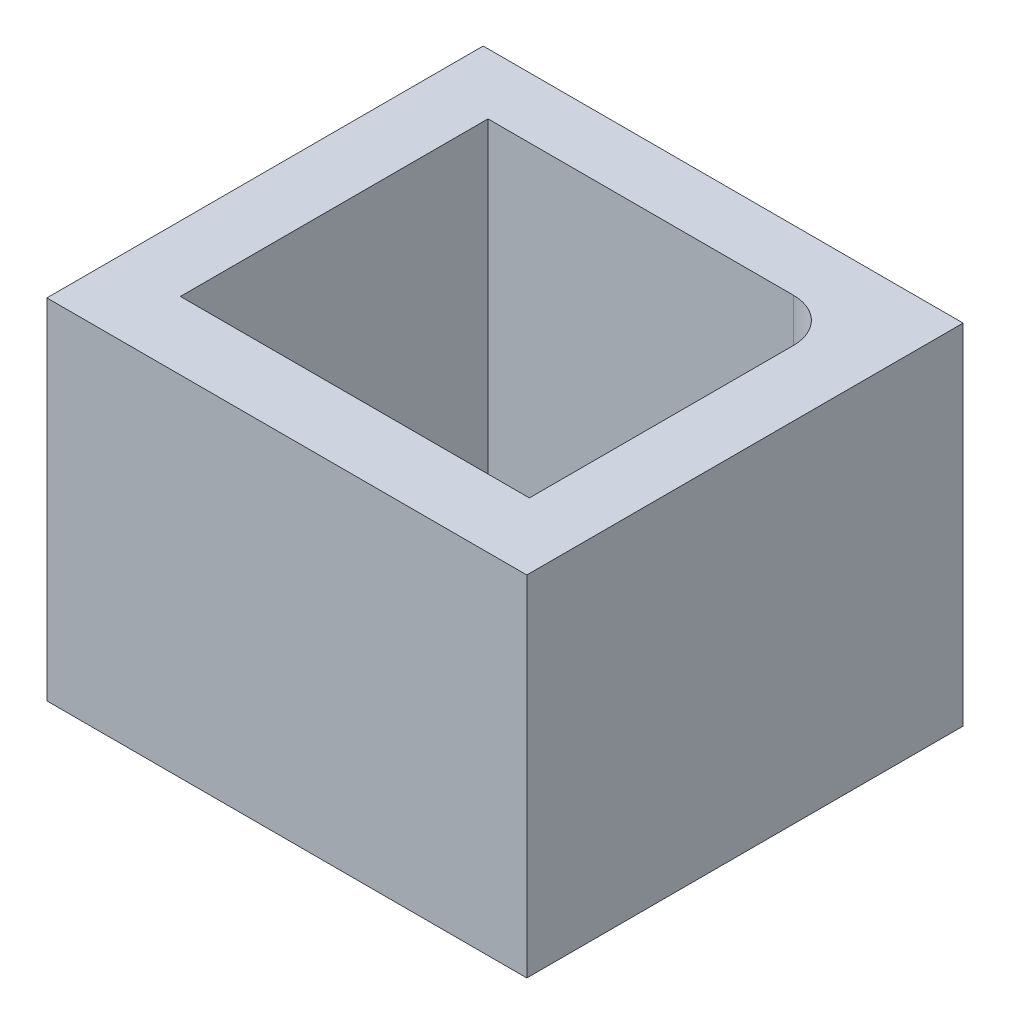
from build123d import *

# Parameters (mm, degrees)
CROQUIS1_R                              = 15.25
CROQUIS1_R_2                            = 2.125
SOPORTE_CAJA_REDUCTORA_DEPTH            = 20
CROQUIS3_R                              = 2.125
CORTAR_EXTRUIR1_DEPTH                   = 51.423828692
REDONDEO1_R                             = 5
BOSS_EXTRUDE1_DEPTH                     = 20
CUT_EXTRUDE1_REACH                      = 55.852
SKETCH2_R                               = 1.625
CUT_EXTRUDE2_DEPTH                      = 2
SKETCH4_R                               = 1.625
CUT_EXTRUDE3_DEPTH                      = 63.291652731
CUT_EXTRUDE4_START                      = -4.5
CUT_EXTRUDE4_DEPTH                      = 2
CROQUIS6_W                              = 4.75
CROQUIS6_H                              = 4.75
CORTAR_EXTRUIR17_DEPTH                  = 42.231056256
CROQUIS7_W                              = 60
CROQUIS7_H                              = 20
CORTAR_EXTRUIR18_DEPTH                  = 51.423828692
SALIENTE_EXTRUIR2_DEPTH                 = 49
SOPORTE_START                           = -15
SOPORTE_MOTOR_DEPTH                     = 15
CROQUIS12_R                             = 2.125
AGUJEROS_DE_SUJECION_A_BASE_DEPTH       = 84.087679592
TUERCA_START                            = -4
TUERCA_AGUJERO_DE_SUJECION_A_BASE_DEPTH = 10
SALIENTE_EXTRUIR4_DEPTH                 = 15
CORTAR_EXTRUIR19_DEPTH                  = 25
CROQUIS14_W                             = 50
CROQUIS14_H                             = 118
CORTAR_EXTRUIR22_DEPTH                  = 146.556045907
CROQUIS15_W                             = 10
CROQUIS15_H                             = 7
CORTAR_EXTRUIR23_DEPTH                  = 42.231056256
CORTAR_EXTRUIR24_DEPTH                  = 42.231056256
CROQUIS18_W                             = 40
CROQUIS18_H                             = 10
CORTAR_EXTRUIR25_DEPTH                  = 44.27311521
SALIENTE_EXTRUIR5_DEPTH                 = 10
CROQUIS20_R                             = 1
CORTAR_EXTRUIR26_DEPTH                  = 49.229270158
CORTAR_EXTRUIR27_REACH                  = 62.959
CORTAR_EXTRUIR27_END_RADIUS             = 15.25
CROQUIS21_R                             = 1.625
CROQUIS22_R                             = 2.125
CROQUIS22_R_2                           = 1
SALIENTE_EXTRUIR6_DEPTH                 = 10
CROQUIS23_R                             = 1.625
CORTAR_EXTRUIR28_DEPTH                  = 52.269508521
CORTAR_EXTRUIR29_START                  = -3
CORTAR_EXTRUIR29_DEPTH                  = 10
SALIENTE_EXTRUIR7_DEPTH                 = 10
CORTAR_EXTRUIR30_REACH                  = 72.235
CROQUIS27_R                             = 1.625
CORTAR_EXTRUIR31_REACH                  = 75.235
CORTAR_EXTRUIR31_START                  = -3
CORTAR_EXTRUIR32_REACH                  = 58.612
CROQUIS29_R                             = 1.625
CORTAR_EXTRUIR33_REACH                  = 61.112
CORTAR_EXTRUIR33_START                  = -2.5
CROQUIS35_W                             = 13.305418987
CROQUIS35_H                             = 6.826864192
CORTAR_EXTRUIR34_DEPTH                  = 63.931555098
CORTAR_EXTRUIR34_DEPTH_BACK             = 63.931555098
CORTAR_EXTRUIR35_START                  = -3
CORTAR_EXTRUIR35_DEPTH                  = 10
SALIENTE_EXTRUIR8_DEPTH                 = 10
SALIENTE_EXTRUIR9_DEPTH                 = 13
SALIENTE_EXTRUIR10_DEPTH                = 3
CROQUIS40_W                             = 106.583537839
CROQUIS40_H                             = 47.391515964
CORTAR_EXTRUIR36_DEPTH                  = 80.887064817
CORTAR_EXTRUIR36_DEPTH_BACK             = 80.887064817
CORTAR_EXTRUIR37_DEPTH                  = 67.2524009
CORTAR_EXTRUIR37_DEPTH_BACK             = 67.2524009
CORTAR_EXTRUIR38_DEPTH                  = 79.704784639
CORTAR_EXTRUIR38_DEPTH_BACK             = 79.704784639
SALIENTE_EXTRUIR11_DEPTH                = 10
CORTAR_EXTRUIR39_DEPTH                  = 63.9908649
CROQUIS45_W                             = 31.470301378
CROQUIS45_H                             = 10
CROQUIS45_R                             = 1.625
SALIENTE_EXTRUIR12_DEPTH                = 2.5
SALIENTE_EXTRUIR13_DEPTH                = 10
CORTAR_EXTRUIR40_START                  = -2
CROQUIS47_R                             = 1.625
CORTAR_EXTRUIR40_DEPTH                  = 10
CORTAR_EXTRUIR41_START                  = -12
CROQUIS48_R                             = 1.625
CORTAR_EXTRUIR41_DEPTH                  = 12
CROQUIS49_W                             = 34.796066513
CROQUIS49_H                             = 42.211026982
CORTAR_EXTRUIR42_DEPTH                  = 52.795622989
CORTAR_EXTRUIR42_DEPTH_BACK             = 52.795622989
CROQUIS51_R                             = 15.25
CROQUIS51_R_2                           = 14.25
SALIENTE_EXTRUIR14_DEPTH                = 10
CORTAR_EXTRUIR43_DEPTH                  = 10
CORTAR_EXTRUIR44_DEPTH                  = 10
CORTAR_EXTRUIR45_DEPTH                  = 10
SALIENTE_EXTRUIR15_DEPTH                = 10
CROQUIS56_W                             = 55
CROQUIS56_H                             = 50
SALIENTE_EXTRUIR16_DEPTH                = 5
CROQUIS57_W                             = 42.651963039
CROQUIS57_H                             = 12.802181648
CORTAR_EXTRUIR46_DEPTH                  = 71.545387859
CORTAR_EXTRUIR46_DEPTH_BACK             = 71.545387859
CROQUIS58_R                             = 2.125
CORTAR_EXTRUIR47_DEPTH                  = 5
CROQUIS59_W                             = 55
CROQUIS59_H                             = 50
SALIENTE_EXTRUIR17_DEPTH                = 40


with BuildPart() as part:
    # Croquis1 → Soporte caja reductora (new body)
    with BuildSketch(Plane(origin=(0, 0, 0), x_dir=(1, 0, 0), z_dir=(0, 1, 0))):
        Polygon((-30, -15.25), (-20, -15.25), (-20, -20), (20, -20), (20, -15.25), (30, -15.25), (30, -7.25), (20, -4.25), (20, 20), (-20, 20), (-20, -4.25), (-30, -7.25), align=None)
        with Locations(Location((0, 0, 0), (0, 0, 270))):
            Circle(CROQUIS1_R, mode=Mode.SUBTRACT)
        with Locations(Location((-15, 15, 0), (0, 0, 270))):
            Circle(CROQUIS1_R_2, mode=Mode.SUBTRACT)
        with Locations(Location((15, 15, 0), (0, 0, 270))):
            Circle(CROQUIS1_R_2, mode=Mode.SUBTRACT)
    extrude(amount=-SOPORTE_CAJA_REDUCTORA_DEPTH)

    # Croquis3 → Cortar-Extruir1 (cut, through all)
    with BuildSketch(Plane.XY.offset(15.25)):
        with Locations((-23.5, -10)):
            Circle(CROQUIS3_R)
        with Locations((23.5, -10)):
            Circle(CROQUIS3_R)
    extrude(amount=-CORTAR_EXTRUIR1_DEPTH, mode=Mode.SUBTRACT)

    # Redondeo1
    redondeo1_edges = [part.edges().sort_by_distance(p)[0] for p in [
        (-20, -10, -20),
        (20, -10, -20),
    ]]
    fillet(redondeo1_edges, radius=REDONDEO1_R)

    # Sketch1 → Boss-Extrude1 (add)
    with BuildSketch(Plane(origin=(0, 0, 0), x_dir=(1, 0, 0), z_dir=(0, 1, 0))):
        with BuildLine():
            Line((25.5, 15), (20, 15))
            ThreePointArc((20, 15), (18.535533906, 18.535533906), (15, 20))
            Line((15, 20), (30, 20))
            Line((30, 20), (30, 8))
            Line((30, 8), (25.5, 8))
            Line((25.5, 8), (25.5, 15))
        make_face()
    extrude(amount=-BOSS_EXTRUDE1_DEPTH)

    # Sketch2 → Cut-Extrude1 (cut, up to next)
    with BuildSketch(Plane(origin=(0, 0, -20), x_dir=(-1, 0, 0), z_dir=(0, 0, -1)), mode=Mode.PRIVATE) as cut_extrude1_sk1:
        with Locations((-22.75, -10)):
            Circle(SKETCH2_R)
    cut_extrude1_tool1 = extrude(cut_extrude1_sk1.sketch, amount=-CUT_EXTRUDE1_REACH, mode=Mode.PRIVATE) & part.part
    add(cut_extrude1_tool1.solids().sort_by_distance((22.75, -10, -20))[0], mode=Mode.SUBTRACT)

    # Sketch3 → Cut-Extrude2 (cut)
    with BuildSketch(Plane.XY.offset(-15)):
        Polygon((20, -11.58771324), (22.75, -13.175426481), (25.5, -11.58771324), (25.5, -8.41228676), (22.75, -6.824573519), (20, -8.41228676), align=None)
    extrude(amount=-CUT_EXTRUDE2_DEPTH, mode=Mode.SUBTRACT)

    # Sketch4 → Cut-Extrude3 (cut, through all)
    with BuildSketch(Plane.ZY.offset(-25.5)):
        with Locations((-12.25, -10)):
            Circle(SKETCH4_R)
    extrude(amount=-CUT_EXTRUDE3_DEPTH, mode=Mode.SUBTRACT)

    # Sketch5 → Cut-Extrude4 (cut)
    with BuildSketch(Plane(origin=(30, 0, 0), x_dir=(0, 0, -1), z_dir=(1, 0, 0)).offset(CUT_EXTRUDE4_START)):
        Polygon((15, -11.58771324), (15, -8.41228676), (12.25, -6.824573519), (9.5, -8.41228676), (9.5, -11.58771324), (12.25, -13.175426481), align=None)
    extrude(amount=CUT_EXTRUDE4_DEPTH, mode=Mode.SUBTRACT)

    # Croquis6 → Cortar-Extruir17 (cut, through all)
    with BuildSketch(Plane(origin=(0, 0, 0), x_dir=(1, 0, 0), z_dir=(0, 1, 0))):
        Polygon((0, -15.25), (-15.25, -15.25), (-15.25, -20), (15.25, -20), (15.25, -15.25), align=None)
        with Locations((-17.625, -17.625)):
            Rectangle(CROQUIS6_W, CROQUIS6_H)
        with BuildLine():
            ThreePointArc((0, -15.25), (-10.783378413, -10.783378413), (-15.25, 0))
            Line((-15.25, 0), (-15.25, -15.25))
            Line((-15.25, -15.25), (0, -15.25))
        make_face()
        with BuildLine():
            Line((15.25, -15.25), (15.25, 0))
            ThreePointArc((15.25, 0), (10.783378413, -10.783378413), (0, -15.25))
            Line((0, -15.25), (15.25, -15.25))
        make_face()
        with Locations((17.625, -17.625)):
            Rectangle(CROQUIS6_W, CROQUIS6_H)
    extrude(amount=-CORTAR_EXTRUIR17_DEPTH, mode=Mode.SUBTRACT)


with BuildPart() as body_2:
    # Simetría1: mirrored copy
    add(part.part.mirror(Plane.ZX))

    # Croquis8 → Saliente-Extruir2 (add)
    with BuildSketch(Plane(origin=(0, 20, 0), x_dir=(1, 0, 0), z_dir=(0, 1, 0))):
        with BuildLine():
            Line((-12.664515522, 20), (-11.040489496, 13.939052358))
            Line((-11.040489496, 13.939052358), (-10.315162126, 11.232093763))
            ThreePointArc((-10.315162126, 11.232093763), (0, 15.25), (10.315162126, 11.232093763))
            Line((10.315162126, 11.232093763), (10.817418481, 13.87928066))
            Line((10.817418481, 13.87928066), (11.978715476, 20))
            Line((11.978715476, 20), (-12.664515522, 20))
        make_face()
    extrude(amount=SALIENTE_EXTRUIR2_DEPTH)

    # Croquis9 → Soporte motor (add)
    with BuildSketch(Plane(origin=(0, 69, 0), x_dir=(1, 0, 0), z_dir=(0, 1, 0)).offset(SOPORTE_START)):
        with BuildLine():
            Line((-20, 15), (-20, -4.25))
            Line((-20, -4.25), (-30, -7.25))
            Line((-30, -7.25), (-30, -15.25))
            Line((-30, -15.25), (0, -15.25))
            Line((0, -15.25), (0, -14.75))
            ThreePointArc((0, -14.75), (-10.429825023, 10.429825023), (14.75, 0))
            Line((14.75, 0), (20, 0))
            Line((20, 0), (20, 13.936837101))
            Line((20, 13.936837101), (12.664515522, 20))
            Line((12.664515522, 20), (-15, 20))
            ThreePointArc((-15, 20), (-18.535533906, 18.535533906), (-20, 15))
        make_face()
    extrude(amount=-SOPORTE_MOTOR_DEPTH)

    # Croquis12 → Agujeros de sujecion a base (cut, through all)
    with BuildSketch(Plane.XY.offset(15.25)):
        with Locations((-23.5, 46.5)):
            Circle(CROQUIS12_R)
    extrude(amount=-AGUJEROS_DE_SUJECION_A_BASE_DEPTH, mode=Mode.SUBTRACT)

    # Croquis13 → Tuerca Agujero de sujecion a base (cut)
    with BuildSketch(Plane.XY.offset(15.25).offset(TUERCA_START)):
        Polygon((-20, 44.479274058), (-20, 48.520725942), (-23.5, 50.541451884), (-27, 48.520725942), (-27, 44.479274058), (-23.5, 42.458548116), align=None)
    extrude(amount=-TUERCA_AGUJERO_DE_SUJECION_A_BASE_DEPTH, mode=Mode.SUBTRACT)

    # Croquis10 → Saliente-Extruir4 (add)
    with BuildSketch(Plane(origin=(0, 69, 0), x_dir=(1, 0, 0), z_dir=(0, 1, 0))):
        with BuildLine():
            ThreePointArc((10.315162126, 11.232093763), (0, 15.25), (-10.315162126, 11.232093763))
            Line((-10.315162126, 11.232093763), (-10.16850369, 10.684757026))
            ThreePointArc((-10.16850369, 10.684757026), (0, 14.75), (10.16850369, 10.684757026))
            Line((10.16850369, 10.684757026), (10.315162126, 11.232093763))
        make_face()
    extrude(amount=-SALIENTE_EXTRUIR4_DEPTH)

    # Croquis11 → Cortar-Extruir19 (cut)
    with BuildSketch(Plane.XZ):
        with BuildLine():
            Line((15.25, 4.25), (20, 4.25))
            Line((20, 4.25), (21.972856468, 4.84185694))
            ThreePointArc((21.972856468, 4.84185694), (19.948931102, 10.40625523), (16.543503257, 15.25))
            Line((16.543503257, 15.25), (15.25, 15.25))
            Line((15.25, 15.25), (15.25, 4.25))
        make_face()
        with BuildLine():
            Line((21.972856468, 4.84185694), (30, 7.25))
            Line((30, 7.25), (30, 15.25))
            Line((30, 15.25), (16.543503257, 15.25))
            ThreePointArc((16.543503257, 15.25), (19.948931102, 10.40625523), (21.972856468, 4.84185694))
        make_face()
        with BuildLine():
            ThreePointArc((20, -15), (18.535533906, -18.535533906), (15, -20))
            Line((15, -20), (30, -20))
            Line((30, -20), (30, -8))
            Line((30, -8), (25.5, -8))
            Line((25.5, -8), (25.5, -15))
            Line((25.5, -15), (20, -15))
        make_face()
    extrude(amount=-CORTAR_EXTRUIR19_DEPTH, mode=Mode.SUBTRACT)

    # Simetría2: body 2 across face


with BuildPart() as part_1:
    add(part.part)

    # Croquis7 → Cortar-Extruir18 (cut, through all)
    with BuildSketch(Plane(origin=(0, 0, -20), x_dir=(-1, 0, 0), z_dir=(0, 0, -1))):
        with Locations((0, -10)):
            Rectangle(CROQUIS7_W, CROQUIS7_H)
    extrude(amount=-CORTAR_EXTRUIR18_DEPTH, mode=Mode.SUBTRACT)


with BuildPart() as body_2_1:
    add(body_2.part)
    add(body_2.part.mirror(Plane(origin=(-0.229209569, 69, -16.663998028), x_dir=(0, 0, 1), z_dir=(0, 1, 0))))

    # Croquis14 → Cortar-Extruir22 (cut, through all)
    with BuildSketch(Plane.XY.offset(15.25)):
        with Locations((-5, 79)):
            Rectangle(CROQUIS14_W, CROQUIS14_H)
    extrude(amount=-CORTAR_EXTRUIR22_DEPTH, mode=Mode.SUBTRACT)

    # Croquis15 → Cortar-Extruir23 (cut, through all)
    with BuildSketch(Plane.XZ):
        with Locations((-25, 7.75)):
            Rectangle(CROQUIS15_W, CROQUIS15_H)
    extrude(amount=-CORTAR_EXTRUIR23_DEPTH, mode=Mode.SUBTRACT)

    # Croquis16 → Cortar-Extruir24 (cut, through all)
    with BuildSketch(Plane.XZ):
        Polygon((-30, 15.25), (-15.25, 15.25), (-15.25, 12.75), (-20, 12.75), (-20, 11.25), (-30, 11.25), (-30, 12.75), align=None)
    extrude(amount=-CORTAR_EXTRUIR24_DEPTH, mode=Mode.SUBTRACT)

    # Croquis18 → Cortar-Extruir25 (cut, through all)
    with BuildSketch(Plane(origin=(0, 0, -20), x_dir=(-1, 0, 0), z_dir=(0, 0, -1))):
        with Locations((0, 5)):
            Rectangle(CROQUIS18_W, CROQUIS18_H)
    extrude(amount=-CORTAR_EXTRUIR25_DEPTH, mode=Mode.SUBTRACT)

    # Croquis19 → Saliente-Extruir5 (add)
    with BuildSketch(Plane(origin=(0, 20, 0), x_dir=(1, 0, 0), z_dir=(0, 1, 0))):
        Polygon((-20, -12.75), (-34, -12.75), (-34, -7.75), (-24, -7.75), (-20, -3.75), align=None)
    extrude(amount=-SALIENTE_EXTRUIR5_DEPTH)

    # Croquis20 → Cortar-Extruir26 (cut, through all)
    with BuildSketch(Plane(origin=(0, 0, 7.75), x_dir=(-1, 0, 0), z_dir=(0, 0, -1))):
        with Locations((29, 15)):
            Circle(CROQUIS20_R)
    extrude(amount=-CORTAR_EXTRUIR26_DEPTH, mode=Mode.SUBTRACT)

    # Cortar-Extruir27: up to this cylinder (the profile starts outside it)
    cortar_extruir27_end = Plane(origin=(0, 15, 0), z_dir=(0, -1, 0)) * Cylinder(CORTAR_EXTRUIR27_END_RADIUS, 157.418, mode=Mode.PRIVATE)
    # Croquis21 → Cortar-Extruir27 (cut, up to the surface)
    with BuildSketch(Plane(origin=(20, 0, 0), x_dir=(0, 0, -1), z_dir=(1, 0, 0)), mode=Mode.PRIVATE) as cortar_extruir27_sk1:
        with Locations((4.75, 15)):
            Circle(CROQUIS21_R)
    cortar_extruir27_tool1 = extrude(cortar_extruir27_sk1.sketch, amount=-CORTAR_EXTRUIR27_REACH, mode=Mode.PRIVATE) - cortar_extruir27_end
    add(cortar_extruir27_tool1.solids().sort_by_distance((20, 15, -4.75))[0], mode=Mode.SUBTRACT)

    # Croquis22 → Saliente-Extruir6 (add)
    with BuildSketch(Plane.XZ.offset(-10)):
        with Locations((-15, -15)):
            Circle(CROQUIS22_R)
        with Locations(Location((-15, -15, 0), (0, 0, 270))):
            Circle(CROQUIS22_R_2, mode=Mode.SUBTRACT)
        with Locations((15, -15)):
            Circle(CROQUIS22_R)
        with Locations(Location((15, -15, 0), (0, 0, 270))):
            Circle(CROQUIS22_R_2, mode=Mode.SUBTRACT)
    extrude(amount=-SALIENTE_EXTRUIR6_DEPTH)

    # Croquis23 → Cortar-Extruir28 (cut, through all)
    with BuildSketch(Plane(origin=(0, 0, -20), x_dir=(-1, 0, 0), z_dir=(0, 0, -1))):
        with Locations((0, 15)):
            Circle(CROQUIS23_R)
    extrude(amount=-CORTAR_EXTRUIR28_DEPTH, mode=Mode.SUBTRACT)

    # Croquis24 → Cortar-Extruir29 (cut)
    with BuildSketch(Plane(origin=(0, 0, -20), x_dir=(-1, 0, 0), z_dir=(0, 0, -1)).offset(CORTAR_EXTRUIR29_START)):
        Polygon((1.58771324, 12.25), (3.175426481, 15), (1.58771324, 17.75), (-1.58771324, 17.75), (-3.175426481, 15), (-1.58771324, 12.25), align=None)
    extrude(amount=-CORTAR_EXTRUIR29_DEPTH, mode=Mode.SUBTRACT)

    # Croquis26 → Saliente-Extruir7 (add)
    with BuildSketch(Plane.XZ.offset(-10)):
        Polygon((-34, 7.75), (-34, 12.75), (-58.825, 12.75), (-39.160527763, -4.104491148), (-20, -4.104491148), (-20, -0.104491148), (-35.732113118, -0.104491148), (-29, 7.75), align=None)
        Polygon((-34.268209086, 7.75), (-39.594516123, 1.535690951), (-46.844874897, 7.75), align=None, mode=Mode.SUBTRACT)
    extrude(amount=-SALIENTE_EXTRUIR7_DEPTH)

    # Croquis27 → Cortar-Extruir30 (cut, up to next)
    with BuildSketch(Plane.XY.offset(12.75), mode=Mode.PRIVATE) as cortar_extruir30_sk1:
        with Locations((-40.544874897, 15)):
            Circle(CROQUIS27_R)
    cortar_extruir30_tool1 = extrude(cortar_extruir30_sk1.sketch, amount=-CORTAR_EXTRUIR30_REACH, mode=Mode.PRIVATE) & body_2_1.part
    # Croquis27 → Cortar-Extruir30 (cut, up to next)
    with BuildSketch(Plane.XY.offset(12.75), mode=Mode.PRIVATE) as cortar_extruir30_sk2:
        with Locations((-29, 15)):
            Circle(CROQUIS27_R)
    cortar_extruir30_tool2 = extrude(cortar_extruir30_sk2.sketch, amount=-CORTAR_EXTRUIR30_REACH, mode=Mode.PRIVATE) & body_2_1.part
    add(cortar_extruir30_tool1.solids().sort_by_distance((-40.544875, 15, 12.75))[0], mode=Mode.SUBTRACT)
    add(cortar_extruir30_tool2.solids().sort_by_distance((-29, 15, 12.75))[0], mode=Mode.SUBTRACT)

    # Croquis28 → Cortar-Extruir31 (cut, up to next)
    with BuildSketch(Plane.XY.offset(12.75).offset(CORTAR_EXTRUIR31_START), mode=Mode.PRIVATE) as cortar_extruir31_sk1:
        Polygon((-38.957161657, 12.25), (-37.369448416, 15), (-38.957161657, 17.75), (-42.132588137, 17.75), (-43.720301378, 15), (-42.132588137, 12.25), align=None)
    cortar_extruir31_tool1 = extrude(cortar_extruir31_sk1.sketch, amount=-CORTAR_EXTRUIR31_REACH, mode=Mode.PRIVATE) & body_2_1.part
    # Croquis28 → Cortar-Extruir31 (cut, up to next)
    with BuildSketch(Plane.XY.offset(12.75).offset(CORTAR_EXTRUIR31_START), mode=Mode.PRIVATE) as cortar_extruir31_sk2:
        Polygon((-27.41228676, 12.25), (-25.824573519, 15), (-27.41228676, 17.75), (-30.58771324, 17.75), (-32.175426481, 15), (-30.58771324, 12.25), align=None)
    cortar_extruir31_tool2 = extrude(cortar_extruir31_sk2.sketch, amount=-CORTAR_EXTRUIR31_REACH, mode=Mode.PRIVATE) & body_2_1.part
    add(cortar_extruir31_tool1.solids().sort_by_distance((-40.544875, 15, 9.75))[0], mode=Mode.SUBTRACT)
    add(cortar_extruir31_tool2.solids().sort_by_distance((-29, 15, 9.75))[0], mode=Mode.SUBTRACT)

    # Croquis29 → Cortar-Extruir32 (cut, up to next)
    with BuildSketch(Plane(origin=(-18.612848159, 0, -21.715982563), x_dir=(-0.7592713073348843, 0, 0.6507742172658468), z_dir=(-0.6507742172658468, 0, -0.7592713073348843)), mode=Mode.PRIVATE) as cortar_extruir32_sk1:
        with Locations((33.812368097, 15)):
            Circle(CROQUIS29_R)
    cortar_extruir32_tool1 = extrude(cortar_extruir32_sk1.sketch, amount=-CORTAR_EXTRUIR32_REACH, mode=Mode.PRIVATE) & body_2_1.part
    add(cortar_extruir32_tool1.solids().sort_by_distance((-44.285609, 15, 0.288235))[0], mode=Mode.SUBTRACT)

    # Croquis31 → Cortar-Extruir33 (cut, up to next)
    with BuildSketch(Plane(origin=(-18.612848159, 0, -21.715982563), x_dir=(-0.7592713073348843, 0, 0.6507742172658468), z_dir=(-0.6507742172658468, 0, -0.7592713073348843)).offset(CORTAR_EXTRUIR33_START), mode=Mode.PRIVATE) as cortar_extruir33_sk1:
        Polygon((36.562368097, 16.58771324), (33.812368097, 18.175426481), (31.062368097, 16.58771324), (31.062368097, 13.41228676), (33.812368097, 11.824573519), (36.562368097, 13.41228676), align=None)
    cortar_extruir33_tool1 = extrude(cortar_extruir33_sk1.sketch, amount=-CORTAR_EXTRUIR33_REACH, mode=Mode.PRIVATE) & body_2_1.part
    add(cortar_extruir33_tool1.solids().sort_by_distance((-42.658674, 15, 2.186413))[0], mode=Mode.SUBTRACT)

    # Croquis35 → Cortar-Extruir34 (cut, two sides)
    with BuildSketch(Plane(origin=(0, 20, 0), x_dir=(1, 0, 0), z_dir=(0, 1, 0))) as cortar_extruir34_sk:
        with Locations((17.04227466, -3.413432096)):
            Rectangle(CROQUIS35_W, CROQUIS35_H)
    extrude(amount=CORTAR_EXTRUIR34_DEPTH, mode=Mode.SUBTRACT)
    extrude(cortar_extruir34_sk.sketch, amount=-CORTAR_EXTRUIR34_DEPTH_BACK, mode=Mode.SUBTRACT)

    # Croquis36 → Cortar-Extruir35 (cut)
    with BuildSketch(Plane(origin=(20, 0, 0), x_dir=(0, 0, -1), z_dir=(1, 0, 0)).offset(CORTAR_EXTRUIR35_START)):
        Polygon((7.5, 16.58771324), (4.75, 18.175426481), (2, 16.58771324), (2, 13.41228676), (4.75, 11.824573519), (7.5, 13.41228676), align=None)
    extrude(amount=-CORTAR_EXTRUIR35_DEPTH, mode=Mode.SUBTRACT)

    # Croquis37 → Saliente-Extruir8 (add)
    with BuildSketch(Plane.XZ.offset(-10)):
        Polygon((-39.160527763, -4.104491148), (-20.614919368, -20), (-15, -20), (-19.558128305, -15.637570403), (-33.014002756, -4.104491148), align=None)
    extrude(amount=-SALIENTE_EXTRUIR8_DEPTH)

    # Croquis38 → Saliente-Extruir9 (add)
    with BuildSketch(Plane.XZ.offset(-10)):
        Polygon((-58.825, 12.75), (-38.825, 12.75), (-38.825, 9.75), (-55.324839942, 9.75), align=None)
    extrude(amount=SALIENTE_EXTRUIR9_DEPTH)

    # Croquis39 → Saliente-Extruir10 (add)
    with BuildSketch(Plane.XZ.offset(-10)):
        Polygon((-38.825, 9.75), (-38.825, 7.75), (-38.825, 5.75), (-50.657959865, 5.75), (-52.991399903, 7.75), (-55.324839942, 9.75), align=None)
    extrude(amount=SALIENTE_EXTRUIR10_DEPTH)

    # Simetría3: body 2 across face


with BuildPart() as body_2_2:
    add(body_2_1.part)
    add(body_2_1.part.mirror(Plane(origin=(-18.003999227, 20, -4.220503046), x_dir=(0, 0, 1), z_dir=(0, 1, 0))))

    # Croquis40 → Cortar-Extruir36 (cut, two sides)
    with BuildSketch(Plane(origin=(0, 0, -20), x_dir=(-1, 0, 0), z_dir=(0, 0, -1))) as cortar_extruir36_sk:
        with Locations((22.395502026, -3.695757982)):
            Rectangle(CROQUIS40_W, CROQUIS40_H)
    extrude(amount=CORTAR_EXTRUIR36_DEPTH, mode=Mode.SUBTRACT)
    extrude(cortar_extruir36_sk.sketch, amount=-CORTAR_EXTRUIR36_DEPTH_BACK, mode=Mode.SUBTRACT)

    # Croquis41 → Cortar-Extruir37 (cut, two sides)
    with BuildSketch(Plane.XZ.offset(-20)) as cortar_extruir37_sk:
        Polygon((-19.992980133, -22.302484261), (-20, 3.75), (-24, 7.75), (-56.035110209, 7.75), align=None)
    extrude(amount=CORTAR_EXTRUIR37_DEPTH, mode=Mode.SUBTRACT)
    extrude(cortar_extruir37_sk.sketch, amount=-CORTAR_EXTRUIR37_DEPTH_BACK, mode=Mode.SUBTRACT)

    # Croquis42 → Cortar-Extruir38 (cut, two sides)
    with BuildSketch(Plane(origin=(0, 0, 9.75), x_dir=(-1, 0, 0), z_dir=(0, 0, -1))) as cortar_extruir38_sk:
        Polygon((46.720301378, 20), (46.720301378, 30), (38.825, 30), (33.492952769, 43.760628779), (49.525340398, 48.951442806), (67.200390695, 42.512205152), (65.906601328, 20), (51.713995885, 13.864168239), align=None)
    extrude(amount=CORTAR_EXTRUIR38_DEPTH, mode=Mode.SUBTRACT)
    extrude(cortar_extruir38_sk.sketch, amount=-CORTAR_EXTRUIR38_DEPTH_BACK, mode=Mode.SUBTRACT)

    # Croquis43 → Saliente-Extruir11 (add)
    with BuildSketch(Plane.XZ.offset(-20)):
        Polygon((-19.993600539, -20), (-46.720301378, 7.75), (-43.839252857, 10.524807997), (-17.112552018, -17.225192003), align=None)
    extrude(amount=-SALIENTE_EXTRUIR11_DEPTH)

    # Croquis44 → Cortar-Extruir39 (cut, through all)
    with BuildSketch(Plane(origin=(0, 0, 9.75), x_dir=(-1, 0, 0), z_dir=(0, 0, -1))):
        Polygon((38.957161657, 27.75), (37.369448416, 25), (38.957161657, 22.25), (42.132588137, 22.25), (43.720301378, 25), (42.132588137, 27.75), align=None)
    extrude(amount=CORTAR_EXTRUIR39_DEPTH, mode=Mode.SUBTRACT)

    # Croquis45 → Saliente-Extruir12 (add)
    with BuildSketch(Plane.XY.offset(12.75)):
        with Locations((-30.985150689, 25)):
            Rectangle(CROQUIS45_W, CROQUIS45_H)
        with Locations((-40.544874897, 25)):
            Circle(CROQUIS45_R, mode=Mode.SUBTRACT)
        with Locations((-29, 25)):
            Circle(CROQUIS45_R, mode=Mode.SUBTRACT)
    extrude(amount=SALIENTE_EXTRUIR12_DEPTH)

    # Croquis46 → Saliente-Extruir13 (add)
    with BuildSketch(Plane.XZ.offset(-20)):
        with BuildLine():
            Line((15.25, 0), (20, 0))
            Line((20, 0), (20, 15.25))
            Line((20, 15.25), (7.549834435, 15.25))
            Line((7.549834435, 15.25), (7.549834435, 13.25))
            ThreePointArc((7.549834435, 13.25), (13.185171124, 7.662490615), (15.25, 0))
        make_face()
        with BuildLine():
            Line((-15.25, 0), (-15.25, 15.25))
            Line((-15.25, 15.25), (-7.549834435, 15.25))
            Line((-7.549834435, 15.25), (-7.549834435, 13.25))
            ThreePointArc((-7.549834435, 13.25), (-13.185171124, 7.662490615), (-15.25, 0))
        make_face()
    extrude(amount=-SALIENTE_EXTRUIR13_DEPTH)

    # Croquis47 → Cortar-Extruir40 (cut)
    with BuildSketch(Plane.XY.offset(15.25).offset(CORTAR_EXTRUIR40_START)):
        Polygon((15.41228676, 22.352505966), (17, 25.102505966), (15.41228676, 27.852505966), (12.236860279, 27.852505966), (10.649147039, 25.102505966), (12.236860279, 22.352505966), align=None)
        with Locations((13.824573519, 25.102505966)):
            Circle(CROQUIS47_R, mode=Mode.SUBTRACT)
        Polygon((-12.236860279, 22.352505966), (-15.41228676, 22.352505966), (-17, 25.102505966), (-15.41228676, 27.852505966), (-12.236860279, 27.852505966), (-10.649147039, 25.102505966), align=None)
        with Locations(Location((-13.824573519, 25.102505966, 0), (0, 0, 131.421584744))):
            Circle(CROQUIS47_R, mode=Mode.SUBTRACT)
    extrude(amount=-CORTAR_EXTRUIR40_DEPTH, mode=Mode.SUBTRACT)

    # Croquis48 → Cortar-Extruir41 (cut)
    with BuildSketch(Plane.XY.offset(15.25).offset(CORTAR_EXTRUIR41_START)):
        with Locations((13.824573519, 25.102505966)):
            Circle(CROQUIS48_R)
        with Locations((-13.824573519, 25.102505966)):
            Circle(CROQUIS48_R)
    extrude(amount=CORTAR_EXTRUIR41_DEPTH, mode=Mode.SUBTRACT)

    # Croquis49 → Cortar-Extruir42 (cut, two sides)
    with BuildSketch(Plane.XZ.offset(-20)) as cortar_extruir42_sk:
        with Locations((-37.391633796, 1.105513491)):
            Rectangle(CROQUIS49_W, CROQUIS49_H)
    extrude(amount=CORTAR_EXTRUIR42_DEPTH, mode=Mode.SUBTRACT)
    extrude(cortar_extruir42_sk.sketch, amount=-CORTAR_EXTRUIR42_DEPTH_BACK, mode=Mode.SUBTRACT)

    # Croquis51 → Saliente-Extruir14 (add)
    with BuildSketch(Plane(origin=(0, 30, 0), x_dir=(1, 0, 0), z_dir=(0, 1, 0))):
        Circle(CROQUIS51_R)
        with Locations(Location((0, 0, 0), (0, 0, 270))):
            Circle(CROQUIS51_R_2, mode=Mode.SUBTRACT)
    extrude(amount=-SALIENTE_EXTRUIR14_DEPTH)

    # Croquis52 → Cortar-Extruir43 (cut)
    with BuildSketch(Plane(origin=(0, 0, 13.25), x_dir=(-1, 0, 0), z_dir=(0, 0, -1))):
        Polygon((-10.649147039, 25.102505966), (-12.236860279, 27.852505966), (-15.41228676, 27.852505966), (-17, 25.102505966), (-15.41228676, 22.352505966), (-12.236860279, 22.352505966), align=None)
        Polygon((17, 25.102505966), (15.41228676, 27.852505966), (12.236860279, 27.852505966), (10.649147039, 25.102505966), (12.236860279, 22.352505966), (15.41228676, 22.352505966), align=None)
    extrude(amount=CORTAR_EXTRUIR43_DEPTH, mode=Mode.SUBTRACT)

    # Croquis53 → Cortar-Extruir44 (cut)
    with BuildSketch(Plane.XY.offset(-17)):
        Polygon((3.175426481, 25), (1.58771324, 27.75), (-1.58771324, 27.75), (-3.175426481, 25), (-1.58771324, 22.25), (1.58771324, 22.25), align=None)
    extrude(amount=CORTAR_EXTRUIR44_DEPTH, mode=Mode.SUBTRACT)

    # Croquis54 → Cortar-Extruir45 (cut)
    with BuildSketch(Plane.ZY.offset(-17)):
        Polygon((-4.75, 28.175426481), (-7.5, 26.58771324), (-7.5, 23.41228676), (-4.75, 21.824573519), (-2, 23.41228676), (-2, 26.58771324), align=None)
    extrude(amount=CORTAR_EXTRUIR45_DEPTH, mode=Mode.SUBTRACT)

    # Croquis55 → Saliente-Extruir15 (add)
    with BuildSketch(Plane(origin=(0, 30, 0), x_dir=(1, 0, 0), z_dir=(0, 1, 0))):
        with BuildLine():
            Line((-7.549834435, -13.25), (-7.549834435, -15.25))
            Line((-7.549834435, -15.25), (0, -15.25))
            ThreePointArc((0, -15.25), (-3.905124838, -14.741522988), (-7.549834435, -13.25))
        make_face()
        with BuildLine():
            ThreePointArc((7.549834435, -13.25), (3.905124838, -14.741522988), (0, -15.25))
            Line((0, -15.25), (7.549834435, -15.25))
            Line((7.549834435, -15.25), (7.549834435, -13.25))
        make_face()
    extrude(amount=-SALIENTE_EXTRUIR15_DEPTH)

    # Croquis57 → Cortar-Extruir46 (cut, two sides)
    with BuildSketch(Plane.ZY.offset(27.5)) as cortar_extruir46_sk:
        with Locations((1.32598152, 23.598909176)):
            Rectangle(CROQUIS57_W, CROQUIS57_H)
    extrude(amount=CORTAR_EXTRUIR46_DEPTH, mode=Mode.SUBTRACT)
    extrude(cortar_extruir46_sk.sketch, amount=-CORTAR_EXTRUIR46_DEPTH_BACK, mode=Mode.SUBTRACT)


with BuildPart() as body_2_2_1:
    # Croquis56 → Saliente-Extruir16 (new body)
    with BuildSketch(Plane(origin=(0, 30, 0), x_dir=(1, 0, 0), z_dir=(0, 1, 0))):
        with Locations((0, 1.956478778)):
            Rectangle(CROQUIS56_W, CROQUIS56_H)
        with BuildLine():
            Line((20, -15.25), (20, 15))
            ThreePointArc((20, 15), (18.535533906, 18.535533906), (15, 20))
            Line((15, 20), (-19.993600539, 20))
            Line((-19.993600539, 20), (-19.993600539, -15.25))
            Line((-19.993600539, -15.25), (20, -15.25))
        make_face(mode=Mode.SUBTRACT)
    extrude(amount=SALIENTE_EXTRUIR16_DEPTH)

    # Croquis58 → Cortar-Extruir47 (cut)
    with BuildSketch(Plane.XZ.offset(-30)):
        with Locations(Location((-12.5, 19.25, 0), (0, 0, 270))):
            Circle(CROQUIS58_R)
        with Locations(Location((12.5, 19.25, 0), (0, 0, 270))):
            Circle(CROQUIS58_R)
        with Locations(Location((-12.5, -23.5, 0), (0, 0, 270))):
            Circle(CROQUIS58_R)
        with Locations(Location((12.5, -23.526519471, 0), (0, 0, 270))):
            Circle(CROQUIS58_R)
        with Locations(Location((-23.493600539, 10.125, 0), (0, 0, 270))):
            Circle(CROQUIS58_R)
        with Locations(Location((-23.493600539, -14.875, 0), (0, 0, 270))):
            Circle(CROQUIS58_R)
        with Locations(Location((23.493600539, -14.875, 0), (0, 0, 90))):
            Circle(CROQUIS58_R)
        with Locations(Location((23.493600539, 10.125, 0), (0, 0, 90))):
            Circle(CROQUIS58_R)
    extrude(amount=-CORTAR_EXTRUIR47_DEPTH, mode=Mode.SUBTRACT)

    # Croquis59 → Saliente-Extruir17 (add)
    with BuildSketch(Plane.XZ.offset(-30)):
        with Locations((0, -1.956478778)):
            Rectangle(CROQUIS59_W, CROQUIS59_H)
        with BuildLine():
            Line((-19.993600539, -20), (15, -20))
            ThreePointArc((15, -20), (18.535533906, -18.535533906), (20, -15))
            Line((20, -15), (20, 15.25))
            Line((20, 15.25), (-19.993600539, 15.25))
            Line((-19.993600539, 15.25), (-19.993600539, -20))
        make_face(mode=Mode.SUBTRACT)
    extrude(amount=-SALIENTE_EXTRUIR17_DEPTH)


solid = body_2_2_1.part
